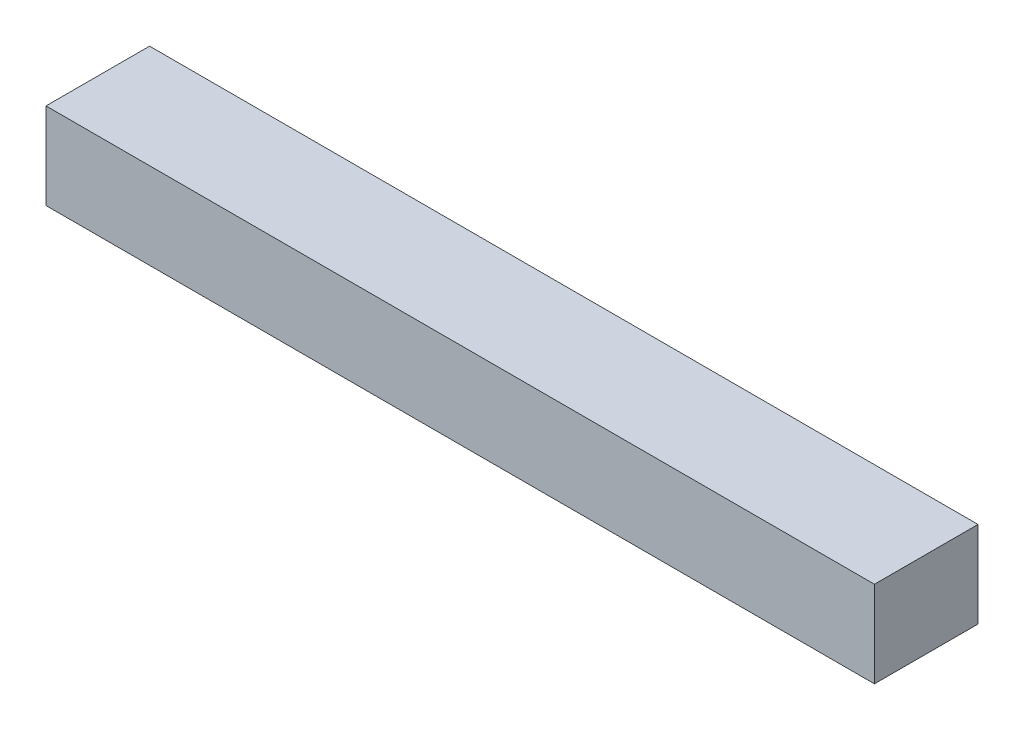
from build123d import *

# Parameters (mm, degrees)
SKETCH1_W           = 304.8
SKETCH1_H           = 31.75
BOSS_EXTRUDE1_DEPTH = 38.1


with BuildPart() as part:
    # Sketch1 → Boss-Extrude1 (new body)
    with BuildSketch(Plane.XY):
        with Locations((152.4, 15.875)):
            Rectangle(SKETCH1_W, SKETCH1_H)
    extrude(amount=BOSS_EXTRUDE1_DEPTH)


solid = part.part
